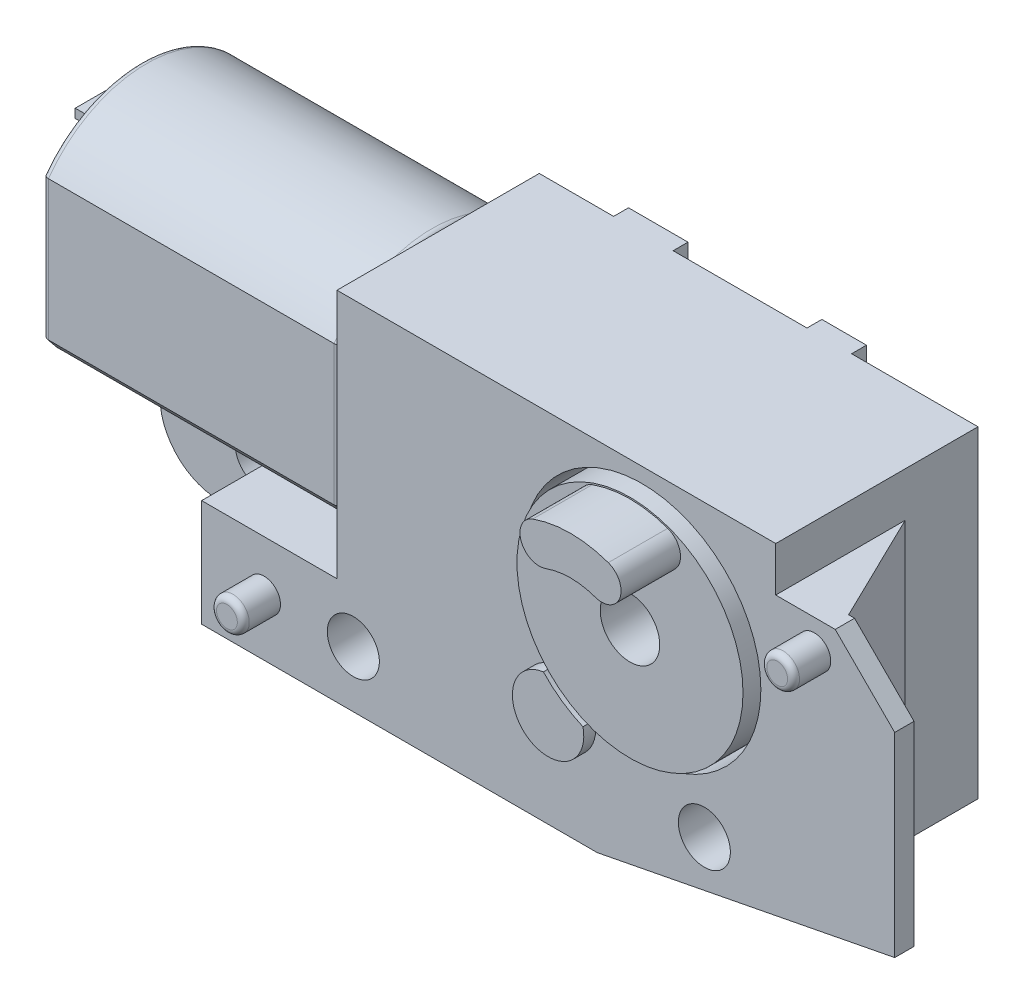
from build123d import *

# Parameters (mm, degrees)
BOSS_EXTRUDE1_DEPTH              = 3.4
BOSS_EXTRUDE2_DEPTH              = 10
FILLET1_R                        = 0.2
SKETCH3_R                        = 4
CUT_EXTRUDE1_DEPTH               = 2
SKETCH4_R                        = 3.8
BOSS_EXTRUDE3_DEPTH              = 2.4
SKETCH5_R                        = 1
CUT_EXTRUDE2_DEPTH               = 8.2
BOSS_EXTRUDE4_DEPTH              = 2
BOSS_EXTRUDE5_DEPTH              = 0.65
BOSS_EXTRUDE6_DEPTH              = 2.9
SKETCH9_R                        = 0.875
CUT_EXTRUDE3_DEPTH               = 6.8
CUT_EXTRUDE3_DEPTH_BACK          = 4.4
SKETCH10_R                       = 0.55
BOSS_EXTRUDE7_DEPTH              = 1.25
FILLET2_R                        = 0.2
BOSS_EXTRUDE8_DEPTH              = 0.4
BOSS_EXTRUDE9_DEPTH              = 1
SKETCH13_R                       = 1.75
BOSS_EXTRUDE10_DEPTH             = 1
FILLET3_R                        = 0.2
SKETCH14_W                       = 1.2
SKETCH14_H                       = 0.3
BOSS_EXTRUDE11_DEPTH             = 1
BOSS_EXTRUDE12_REACH             = 6.5
BOSS_EXTRUDE12_DIRECTION_2_REACH = 9.5
BOSS_EXTRUDE13_DEPTH             = 0.5
SKETCH17_W                       = 4.5
SKETCH17_H                       = 0.5
CUT_EXTRUDE4_DEPTH               = 13


with BuildPart() as part:
    # Sketch1 → Boss-Extrude1 (new body, symmetric)
    with BuildSketch(Plane.XY):
        Polygon((-10.25, 4.5), (4.5, 4.5), (4.5, -6.333718145), (-1.5, -7.5), (-14.8, -7.5), (-14.8, -3.9), (-10.25, -3.9), align=None)
    extrude(amount=BOSS_EXTRUDE1_DEPTH, both=True)

    # Sketch3 → Cut-Extrude1 (cut)
    with BuildSketch(Plane.XY.offset(3.4)):
        Circle(SKETCH3_R)
    extrude(amount=-CUT_EXTRUDE1_DEPTH, mode=Mode.SUBTRACT)

    # Sketch7 → Boss-Extrude5 (add)
    with BuildSketch(Plane.XY.offset(3.4)):
        Polygon((4.5, 3), (4.5, -6.333718145), (8.5, -5.556196909), (8.5, 1), (6.5, 3), align=None)
    extrude(amount=-BOSS_EXTRUDE5_DEPTH)

    # Sketch8 → Boss-Extrude6 (add)
    with BuildSketch(Plane(origin=(0, 0, -3.4), x_dir=(-1, 0, 0), z_dir=(0, 0, -1))):
        with BuildLine():
            Line((14.8, -7.5), (14.8, -3.9))
            Line((14.8, -3.9), (20.1, -3.9))
            Line((20.1, -3.9), (20.1, -5.5))
            ThreePointArc((20.1, -5.5), (19.514213562, -6.914213562), (18.1, -7.5))
            Line((18.1, -7.5), (14.8, -7.5))
        make_face()
    extrude(amount=-BOSS_EXTRUDE6_DEPTH)

    # Sketch9 → Cut-Extrude3 (cut, two sides)
    with BuildSketch(Plane.XY) as cut_extrude3_sk:
        with Locations((-16.7, -5.6)):
            Circle(SKETCH9_R)
        with Locations((-9.7, -5.6)):
            Circle(SKETCH9_R)
        with Locations((2.1, -5.25)):
            Circle(SKETCH9_R)
    extrude(amount=CUT_EXTRUDE3_DEPTH, mode=Mode.SUBTRACT)
    extrude(cut_extrude3_sk.sketch, amount=-CUT_EXTRUDE3_DEPTH_BACK, mode=Mode.SUBTRACT)

    # Sketch10 → Boss-Extrude7 (add)
    with BuildSketch(Plane.XY.offset(3.4)):
        with Locations((-12.7, -5.6)):
            Circle(SKETCH10_R)
        with Locations((5.8, 2)):
            Circle(SKETCH10_R)
    extrude(amount=BOSS_EXTRUDE7_DEPTH)

    # Fillet2
    fillet2_edges = [part.edges().sort_by_distance(p)[0] for p in [
        (-13.25, -5.6, 4.65),
        (5.25, 2, 4.65),
    ]]
    fillet(fillet2_edges, radius=FILLET2_R)

    # Sketch11 → Boss-Extrude8 (add)
    with BuildSketch(Plane.XY.offset(3.4)):
        with BuildLine():
            ThreePointArc((-2.911849918, -2.742467876), (-3.441458618, -4.914912266), (-1.5811655, -3.674223137))
            ThreePointArc((-1.5811655, -3.674223137), (-2.294305745, -3.276608177), (-2.911849918, -2.742467876))
        make_face()
    extrude(amount=BOSS_EXTRUDE8_DEPTH)

    # Sketch12 → Boss-Extrude9 (add)
    with BuildSketch(Plane.ZY.offset(20.1)):
        with BuildLine():
            Line((-1.043577871, -4.401902651), (-0.5, -4.354345749))
            Line((-0.5, -4.354345749), (-0.5, -5.445654251))
            Line((-0.5, -5.445654251), (-1.043577871, -5.398097349))
            ThreePointArc((-1.043577871, -5.398097349), (-1.5, -4.9), (-1.043577871, -4.401902651))
        make_face()
    extrude(amount=BOSS_EXTRUDE9_DEPTH)

    # Boss-Extrude12: up to this face of the body (flat: up to its plane)
    boss_extrude12_end = Plane(part.part.faces().sort_by_distance((5.5, 3, 3.075))[0])
    # Sketch15 → Boss-Extrude12 (add, up to the picked face)
    with BuildSketch(Plane(origin=(0, 0, 0), x_dir=(1, 0, 0), z_dir=(0, 1, 0)), mode=Mode.PRIVATE) as boss_extrude12_sk1:
        Polygon((4.5, -2.75), (6.3, -2.75), (4.5, 0.95), align=None)
    boss_extrude12_tool1 = split(extrude(boss_extrude12_sk1.sketch, amount=BOSS_EXTRUDE12_REACH, mode=Mode.PRIVATE), bisect_by=boss_extrude12_end, keep=Keep.BOTH, mode=Mode.PRIVATE)
    add(boss_extrude12_tool1.solids().sort_by_distance((5.1, 0, 1.516667))[0])

    # Boss-Extrude12 direction 2: up to this face of the body (flat: up to its plane)
    boss_extrude12_direction_2_end = Plane(part.part.faces().sort_by_distance((1.799539171, -6.858634556, 0.18421659))[0])
    # Sketch15 → Boss-Extrude12 direction 2 (add, up to the picked face)
    with BuildSketch(Plane(origin=(0, 0, 0), x_dir=(1, 0, 0), z_dir=(0, 1, 0)), mode=Mode.PRIVATE) as boss_extrude12_direction_2_sk1:
        Polygon((4.5, -2.75), (6.3, -2.75), (4.5, 0.95), align=None)
    boss_extrude12_direction_2_tool1 = split(extrude(boss_extrude12_direction_2_sk1.sketch, amount=-BOSS_EXTRUDE12_DIRECTION_2_REACH, mode=Mode.PRIVATE), bisect_by=boss_extrude12_direction_2_end, keep=Keep.BOTH, mode=Mode.PRIVATE)
    add(boss_extrude12_direction_2_tool1.solids().sort_by_distance((5.1, 0, 1.516667))[0])

    # Sketch16 → Boss-Extrude13 (add)
    with BuildSketch(Plane(origin=(0, 0, -3.4), x_dir=(-1, 0, 0), z_dir=(0, 0, -1))):
        Polygon((7.75, 4.5), (-0.25, 4.5), (-0.25, -7.159834459), (1.5, -7.5), (7.75, -7.5), align=None)
    extrude(amount=BOSS_EXTRUDE13_DEPTH)

    # Sketch17 → Cut-Extrude4 (cut, through all)
    with BuildSketch(Plane(origin=(0, 4.5, 0), x_dir=(1, 0, 0), z_dir=(0, 1, 0))):
        with Locations((-3.5, 3.65)):
            Rectangle(SKETCH17_W, SKETCH17_H)
    extrude(amount=-CUT_EXTRUDE4_DEPTH, mode=Mode.SUBTRACT)


with BuildPart() as body_2:
    # Sketch2 → Boss-Extrude2 (new body)
    with BuildSketch(Plane.ZY.offset(10.25)):
        with BuildLine():
            Line((-3.3, 2.797871376), (-3.3, -1.897871376))
            ThreePointArc((-3.3, -1.897871376), (0, -3.6), (3.3, -1.897871376))
            Line((3.3, -1.897871376), (3.3, 2.797871376))
            ThreePointArc((3.3, 2.797871376), (0, 4.5), (-3.3, 2.797871376))
        make_face()
    extrude(amount=BOSS_EXTRUDE2_DEPTH)

    # Fillet1
    fillet1_edges = [body_2.edges().sort_by_distance(p)[0] for p in [
        (-20.25, -3.6, 0),
        (-20.25, 0.45, 3.3),
        (-20.25, 4.5, 0),
        (-10.25, 0.45, 3.3),
        (-10.25, -3.6, 0),
        (-10.25, 0.45, -3.3),
        (-10.25, 4.5, 0),
        (-20.25, 0.45, -3.3),
    ]]
    fillet(fillet1_edges, radius=FILLET1_R)

    # Sketch13 → Boss-Extrude10 (add)
    with BuildSketch(Plane.ZY.offset(20.25)):
        with Locations((0, 0.45)):
            Circle(SKETCH13_R)
    extrude(amount=BOSS_EXTRUDE10_DEPTH)

    # Fillet3
    fillet3_edges = [body_2.edges().sort_by_distance(p)[0] for p in [
        (-21.25, 0.45, -1.75),
    ]]
    fillet(fillet3_edges, radius=FILLET3_R)

    # Sketch14 → Boss-Extrude11 (add)
    with BuildSketch(Plane.ZY.offset(20.25)):
        with Locations((0.6, 3.05)):
            Rectangle(SKETCH14_W, SKETCH14_H)
        with Locations((-0.6, -2.15)):
            Rectangle(SKETCH14_W, SKETCH14_H)
    extrude(amount=BOSS_EXTRUDE11_DEPTH)


with BuildPart() as body_3:
    # Sketch4 → Boss-Extrude3 (new body)
    with BuildSketch(Plane.XY.offset(1.4)):
        Circle(SKETCH4_R)
    extrude(amount=BOSS_EXTRUDE3_DEPTH)

    # Sketch5 → Cut-Extrude2 (cut, through all)
    with BuildSketch(Plane.XY.offset(3.8)):
        Circle(SKETCH5_R)
    extrude(amount=-CUT_EXTRUDE2_DEPTH, mode=Mode.SUBTRACT)

    # Sketch6 → Boss-Extrude4 (add)
    with BuildSketch(Plane.XY.offset(3.8)):
        with BuildLine():
            ThreePointArc((0.82983871, 2.305182794), (0, 2.45), (-0.82983871, 2.305182794))
            ThreePointArc((-0.82983871, 2.305182794), (-1.661579109, 2.696600613), (-1.27016129, 3.528341012))
            ThreePointArc((-1.27016129, 3.528341012), (0, 3.75), (1.27016129, 3.528341012))
            ThreePointArc((1.27016129, 3.528341012), (1.661579109, 2.696600613), (0.82983871, 2.305182794))
        make_face()
    extrude(amount=BOSS_EXTRUDE4_DEPTH)


solid = Compound([part.part, body_2.part, body_3.part])
